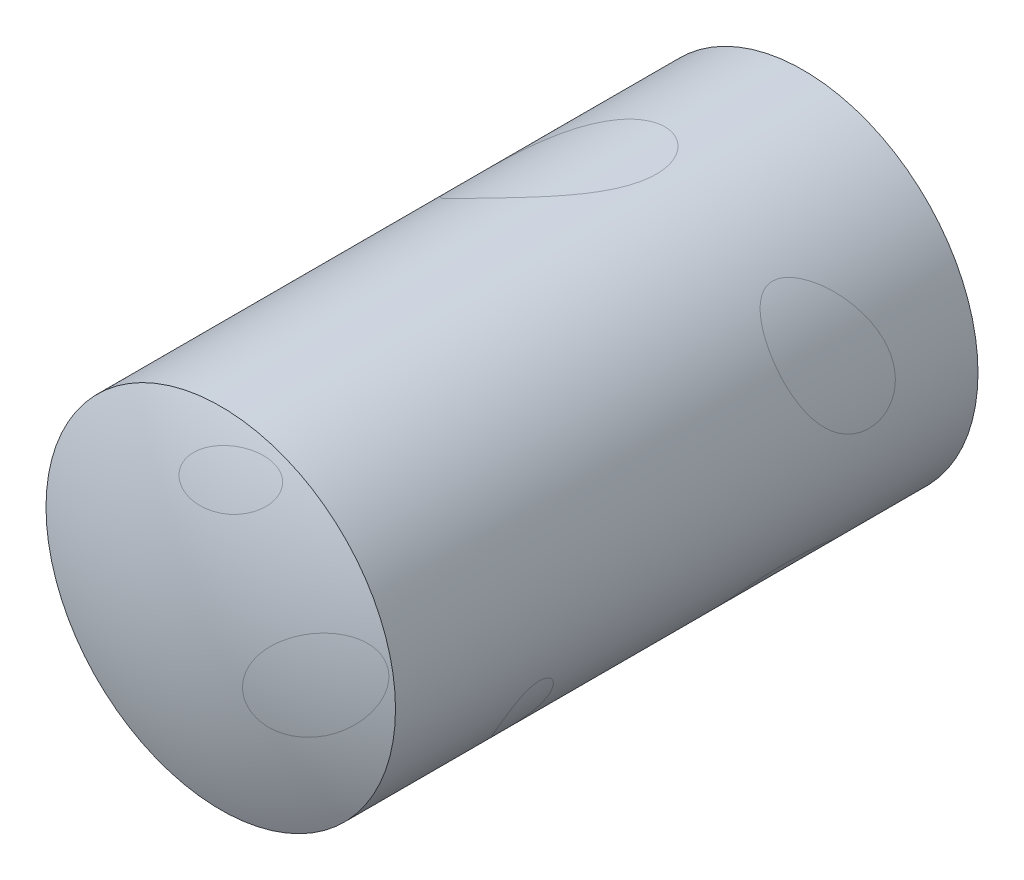
from build123d import *

# Parameters (mm, degrees)
SKETCH2_R           = 6000
BOSS_EXTRUDE1_DEPTH = 20000
DOME1_FACE_RADIUS   = 6000
DOME1_HEIGHT        = 1200
SKETCH8_R           = 5950
CUT_EXTRUDE2_DEPTH  = 19950


with BuildPart() as part:
    # Sketch2 → Boss-Extrude1 (new body)
    with BuildSketch(Plane.XY):
        Circle(SKETCH2_R)
    extrude(amount=BOSS_EXTRUDE1_DEPTH)

    # Dome1: a dome of height H over a round flat face of radius A is a cap of a sphere of radius (A * A + H * H) / (2 * H)
    dome1_r = (DOME1_FACE_RADIUS * DOME1_FACE_RADIUS + DOME1_HEIGHT * DOME1_HEIGHT) / (2 * DOME1_HEIGHT)
    dome1_base = Plane((0, 0, 20000), z_dir=(0, 0, 1))
    with Locations(dome1_base.offset(DOME1_HEIGHT - dome1_r)):
        dome1_ball = Sphere(dome1_r, mode=Mode.PRIVATE)
    add(split(dome1_ball, bisect_by=dome1_base, keep=Keep.TOP, mode=Mode.PRIVATE))

    # Sketch8 → Cut-Extrude2 (cut)
    with BuildSketch(Plane.XY.offset(50)):
        Circle(SKETCH8_R)
    extrude(amount=CUT_EXTRUDE2_DEPTH, mode=Mode.SUBTRACT)


solid = part.part
